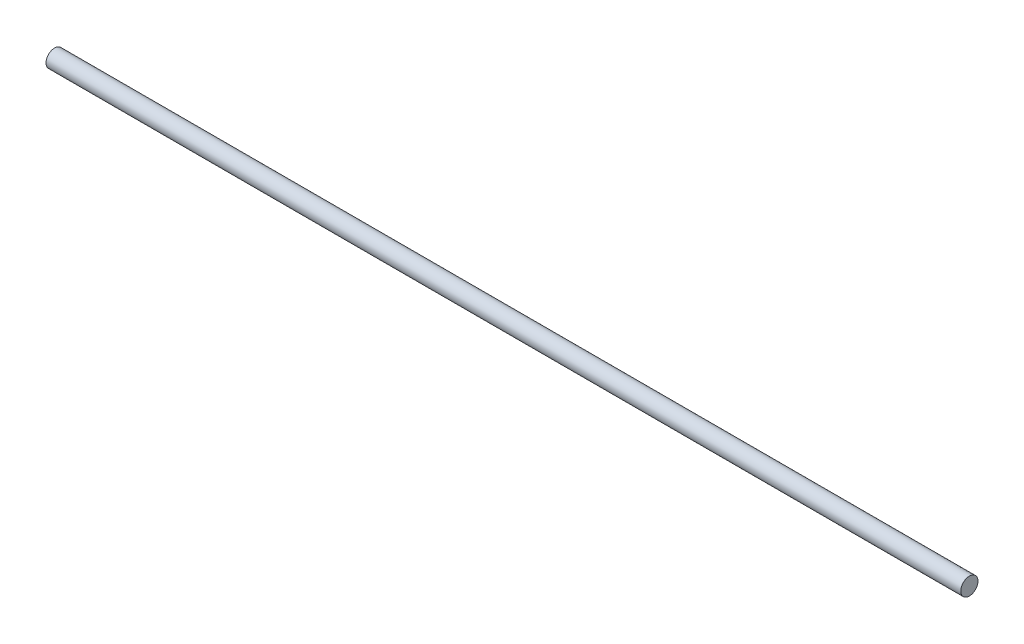
from build123d import *

# Parameters (mm, degrees)
SKETCH1_R           = 3
SKETCH1_R_2         = 0.003
BOSS_EXTRUDE1_DEPTH = 159


with BuildPart() as part:
    # Sketch1 → Boss-Extrude1 (new body, symmetric)
    with BuildSketch(Plane(origin=(0, 0, 0), x_dir=(0, 0, -1), z_dir=(1, 0, 0))):
        Circle(SKETCH1_R)
        Circle(SKETCH1_R_2, mode=Mode.SUBTRACT)
    extrude(amount=BOSS_EXTRUDE1_DEPTH, both=True)


solid = part.part
